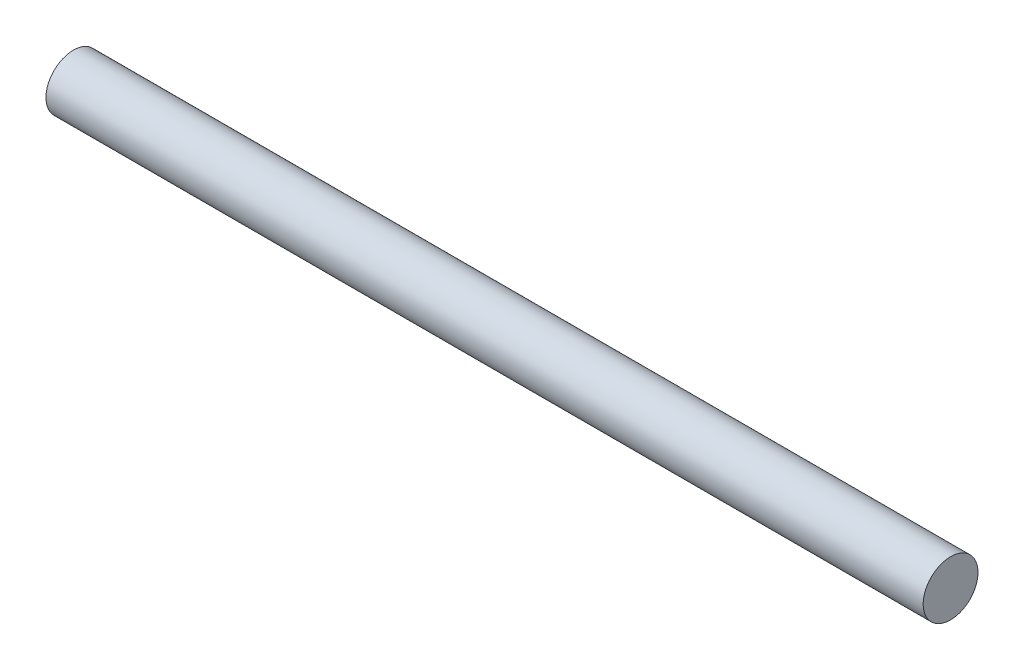
from build123d import *

# Parameters (mm, degrees)
SKETCH1_R           = 2.5
BOSS_EXTRUDE1_DEPTH = 80


with BuildPart() as part:
    # Sketch1 → Boss-Extrude1 (new body)
    with BuildSketch(Plane(origin=(0, 0, 0), x_dir=(0, 0, -1), z_dir=(1, 0, 0))):
        Circle(SKETCH1_R)
    extrude(amount=BOSS_EXTRUDE1_DEPTH)


solid = part.part
